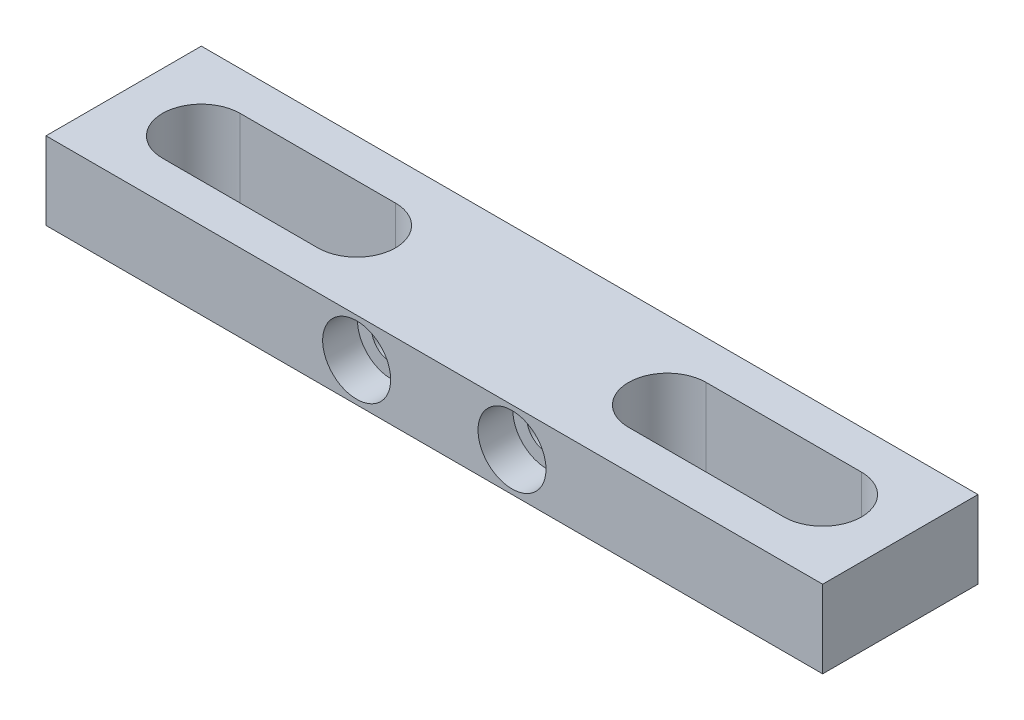
from build123d import *

# Parameters (mm, degrees)
SKETCH2_W                                      = 63.5
SKETCH2_H                                      = 12.7
BOSS_EXTRUDE1_DEPTH                            = 6.35
CBORE_FOR_4_SOCKET_HEAD_CAP_SCREW1_D           = 3.2639
CBORE_FOR_4_SOCKET_HEAD_CAP_SCREW1_CBORE_D     = 5.55752
CBORE_FOR_4_SOCKET_HEAD_CAP_SCREW1_CBORE_DEPTH = 2.8448
CUT_EXTRUDE1_DEPTH                             = 7.35


with BuildPart() as part:
    # Sketch2 → Boss-Extrude1 (new body)
    with BuildSketch(Plane(origin=(0, 0, 0), x_dir=(1, 0, 0), z_dir=(0, 1, 0))):
        with Locations((20.894224422, 2.49179868)):
            Rectangle(SKETCH2_W, SKETCH2_H)
    extrude(amount=BOSS_EXTRUDE1_DEPTH)

    # CBORE for #4 Socket Head Cap Screw1 (through all)
    with Locations(Plane.XY.offset(3.85820132)):
        with Locations((14.544224422, 3.175), (27.244224422, 3.175)):
            CounterBoreHole(CBORE_FOR_4_SOCKET_HEAD_CAP_SCREW1_D / 2, CBORE_FOR_4_SOCKET_HEAD_CAP_SCREW1_CBORE_D / 2, CBORE_FOR_4_SOCKET_HEAD_CAP_SCREW1_CBORE_DEPTH)

    # Sketch8 → Cut-Extrude1 (cut, through all)
    with BuildSketch(Plane(origin=(0, 6.35, 0), x_dir=(1, 0, 0), z_dir=(0, 1, 0))):
        with BuildLine():
            Line((-4.505775578, 5.66679868), (8.194224422, 5.66679868))
            ThreePointArc((8.194224422, 5.66679868), (11.369224422, 2.49179868), (8.194224422, -0.68320132))
            Line((8.194224422, -0.68320132), (-4.505775578, -0.68320132))
            ThreePointArc((-4.505775578, -0.68320132), (-7.680775578, 2.49179868), (-4.505775578, 5.66679868))
        make_face()
        with BuildLine():
            Line((33.594224422, 5.66679868), (46.294224422, 5.66679868))
            ThreePointArc((46.294224422, 5.66679868), (49.469224422, 2.49179868), (46.294224422, -0.68320132))
            Line((46.294224422, -0.68320132), (33.594224422, -0.68320132))
            ThreePointArc((33.594224422, -0.68320132), (30.419224422, 2.49179868), (33.594224422, 5.66679868))
        make_face()
    extrude(amount=-CUT_EXTRUDE1_DEPTH, mode=Mode.SUBTRACT)


solid = part.part
